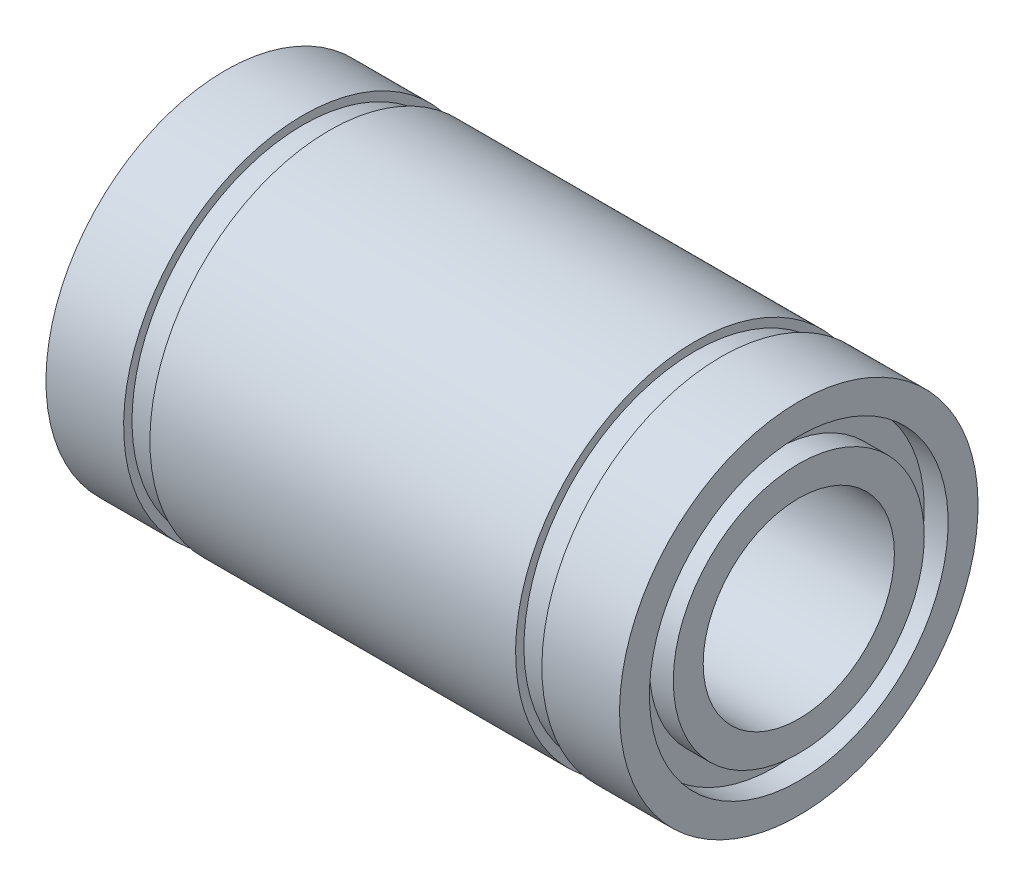
from build123d import *


with BuildPart() as part:
    # Esboço1 → Revolution (revolve)
    with BuildSketch(Plane.XY):
        Polygon((-12, 7.5), (-8.75, 7.5), (-8.75, 7.15), (-7.65, 7.15), (-7.65, 7.5), (7.65, 7.5), (7.65, 7.15), (8.75, 7.15), (8.75, 7.5), (12, 7.5), (12, 6.25), (11, 6.25), (11, 5.25), (12, 5.25), (12, 4), (-12, 4), (-12, 5.25), (-11, 5.25), (-11, 6.25), (-12, 6.25), align=None)
    revolve(axis=Axis((0, 0, 0), (-1, 0, 0)))


solid = part.part
